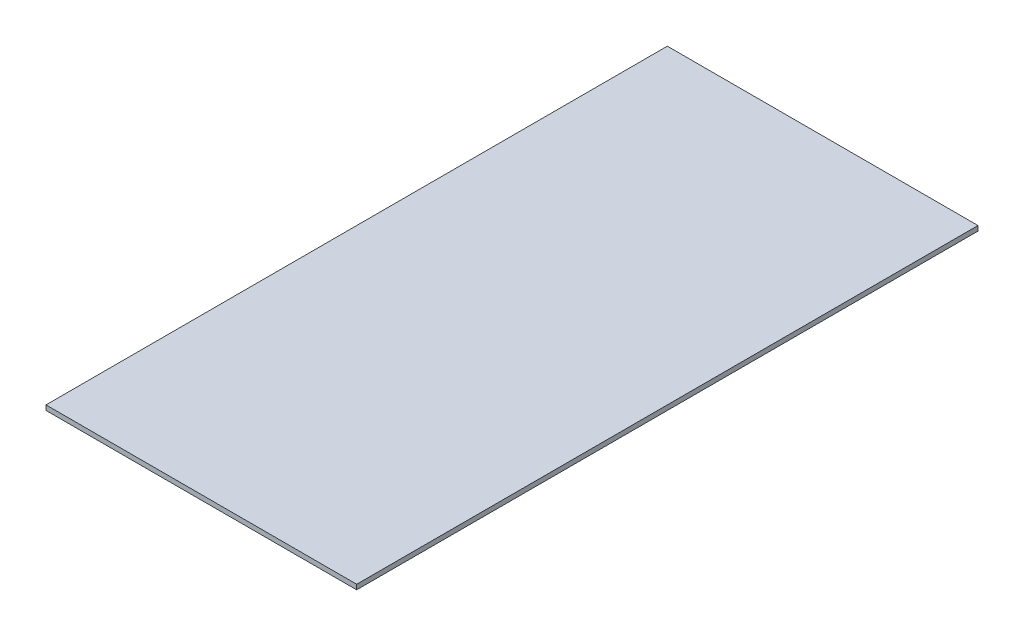
from build123d import *

# Parameters (mm, degrees)
SKETCH1_W           = 203.2
SKETCH1_H           = 406.4
BOSS_EXTRUDE1_DEPTH = 3.175


with BuildPart() as part:
    # Sketch1 → Boss-Extrude1 (new body)
    with BuildSketch(Plane(origin=(0, 0, 0), x_dir=(1, 0, 0), z_dir=(0, 1, 0))):
        with Locations((-101.6, -203.2)):
            Rectangle(SKETCH1_W, SKETCH1_H)
    extrude(amount=BOSS_EXTRUDE1_DEPTH)


solid = part.part
